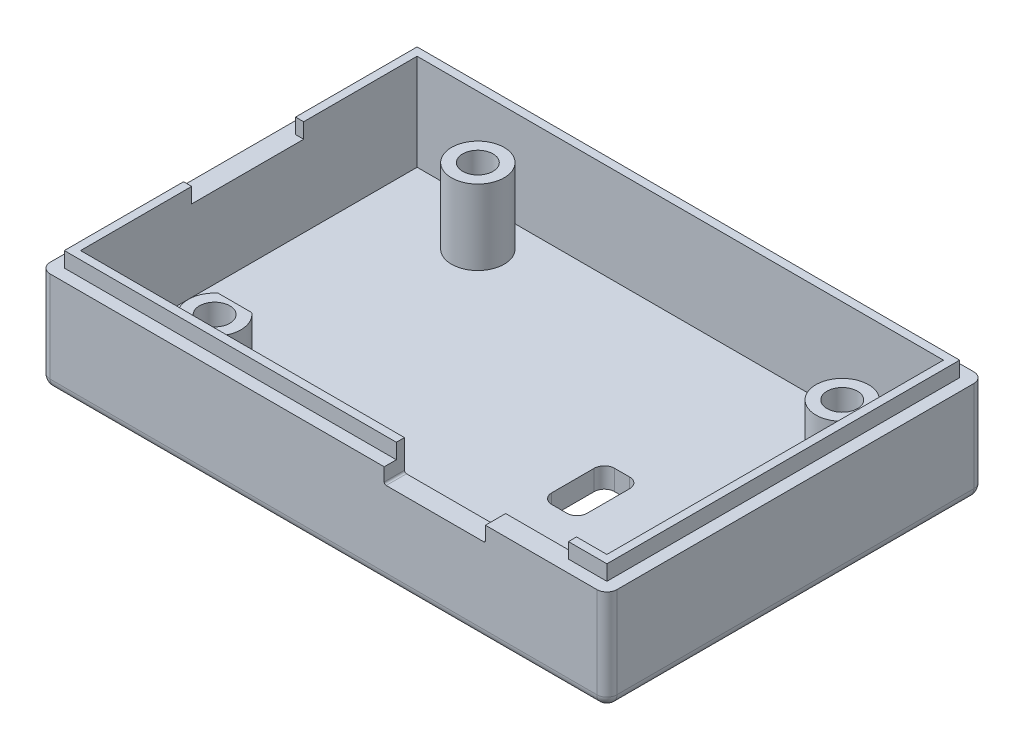
from build123d import *

# Parameters (mm, degrees)
SKETCH1_W           = 56
SKETCH1_H           = 37.25
BOSS_EXTRUDE1_DEPTH = 2
SKETCH2_W           = 56
SKETCH2_H           = 37.25
SKETCH2_W_2         = 52
SKETCH2_H_2         = 33.25
BOSS_EXTRUDE2_DEPTH = 9
SKETCH3_R           = 2.6
SKETCH3_R_2         = 1.5
BOSS_EXTRUDE3_DEPTH = 7.4
SKETCH5_W           = 56
SKETCH5_H           = 37.25
SKETCH5_W_2         = 53.6
SKETCH5_H_2         = 34.85
CUT_EXTRUDE1_DEPTH  = 1
FILLET1_R           = 1
SKETCH7_R           = 1.5
CUT_EXTRUDE2_DEPTH  = 10
CUT_EXTRUDE3_DEPTH  = 3
FILLET2_R           = 1
CUT_EXTRUDE4_DEPTH  = 7.4
SKETCH10_W          = 3.5
SKETCH10_H          = 6.2
CUT_EXTRUDE5_DEPTH  = 10
FILLET3_R           = 1
SKETCH11_W          = 7
SKETCH11_H          = 1
CUT_EXTRUDE6_DEPTH  = 10
FILLET4_R           = 0.2
BOSS_EXTRUDE6_DEPTH = 0.5
SKETCH13_W          = 11.063396545
SKETCH13_H          = 1.5
CUT_EXTRUDE9_DEPTH  = 2
SKETCH14_R          = 2.6
CUT_EXTRUDE10_DEPTH = 2.3


with BuildPart() as part:
    # Sketch1 → Boss-Extrude1 (new body)
    with BuildSketch(Plane(origin=(0, 0, 0), x_dir=(1, 0, 0), z_dir=(0, 1, 0))):
        with Locations((28, 18.625)):
            Rectangle(SKETCH1_W, SKETCH1_H)
    extrude(amount=BOSS_EXTRUDE1_DEPTH)

    # Sketch2 → Boss-Extrude2 (add)
    with BuildSketch(Plane(origin=(0, 2, 0), x_dir=(1, 0, 0), z_dir=(0, 1, 0))):
        with Locations((28, 18.625)):
            Rectangle(SKETCH2_W, SKETCH2_H)
        with Locations((28, 18.625)):
            Rectangle(SKETCH2_W_2, SKETCH2_H_2, mode=Mode.SUBTRACT)
    extrude(amount=BOSS_EXTRUDE2_DEPTH)

    # Sketch3 → Boss-Extrude3 (add)
    with BuildSketch(Plane(origin=(0, 2, 0), x_dir=(1, 0, 0), z_dir=(0, 1, 0))):
        with Locations((12, 5.25)):
            Circle(SKETCH3_R)
        with Locations((12, 5.25)):
            Circle(SKETCH3_R_2, mode=Mode.SUBTRACT)
        with Locations((12, 31.25)):
            Circle(SKETCH3_R)
        with Locations((12, 31.25)):
            Circle(SKETCH3_R_2, mode=Mode.SUBTRACT)
        with Locations((48, 31.25)):
            Circle(SKETCH3_R)
        with Locations((48, 31.25)):
            Circle(SKETCH3_R_2, mode=Mode.SUBTRACT)
    extrude(amount=BOSS_EXTRUDE3_DEPTH)

    # Sketch5 → Cut-Extrude1 (cut)
    with BuildSketch(Plane(origin=(0, 11, 0), x_dir=(1, 0, 0), z_dir=(0, 1, 0))):
        with Locations((28, 18.625)):
            Rectangle(SKETCH5_W, SKETCH5_H)
        with Locations((28, 18.625)):
            Rectangle(SKETCH5_W_2, SKETCH5_H_2, mode=Mode.SUBTRACT)
    extrude(amount=-CUT_EXTRUDE1_DEPTH, mode=Mode.SUBTRACT)

    # Fillet1
    fillet1_edges = [part.edges().sort_by_distance(p)[0] for p in [
        (0, 5, -37.25),
        (56, 5, -37.25),
        (56, 5, 0),
        (0, 5, 0),
    ]]
    fillet(fillet1_edges, radius=FILLET1_R)

    # Sketch7 → Cut-Extrude2 (cut)
    with BuildSketch(Plane(origin=(0, 2, 0), x_dir=(1, 0, 0), z_dir=(0, 1, 0))):
        with Locations((12, 5.25)):
            Circle(SKETCH7_R)
        with Locations((48, 31.25)):
            Circle(SKETCH7_R)
        with Locations((12, 31.25)):
            Circle(SKETCH7_R)
    extrude(amount=-CUT_EXTRUDE2_DEPTH, mode=Mode.SUBTRACT)

    # Sketch8 → Cut-Extrude3 (cut)
    with BuildSketch(Plane.XY):
        Polygon((44, 10), (44, 8.5), (34, 8.5), (34, 10), (34, 11), (44, 11), align=None)
    extrude(amount=-CUT_EXTRUDE3_DEPTH, mode=Mode.SUBTRACT)

    # Fillet2
    fillet2_edges = [part.edges().sort_by_distance(p)[0] for p in [
        (28, 0, -37.25),
        (0, 0, -18.625),
        (56, 0, -18.625),
        (28, 0, 0),
        (0.292893219, 0, -0.292893219),
        (0.292893219, 0, -36.957106781),
        (55.707106781, 0, -0.292893219),
        (55.707106781, 0, -36.957106781),
    ]]
    fillet(fillet2_edges, radius=FILLET2_R)

    # Sketch9 → Cut-Extrude4 (cut)
    with BuildSketch(Plane(origin=(0, 9.4, 0), x_dir=(1, 0, 0), z_dir=(0, 1, 0))):
        with BuildLine():
            Line((12, 7.25), (13.661324773, 7.25))
            ThreePointArc((13.661324773, 7.25), (12, 7.85), (10.338675227, 7.25))
            Line((10.338675227, 7.25), (12, 7.25))
        make_face()
    extrude(amount=-CUT_EXTRUDE4_DEPTH, mode=Mode.SUBTRACT)

    # Sketch10 → Cut-Extrude5 (cut)
    with BuildSketch(Plane(origin=(0, 2, 0), x_dir=(1, 0, 0), z_dir=(0, 1, 0))):
        with Locations((38.25, 16.15)):
            Rectangle(SKETCH10_W, SKETCH10_H)
    extrude(amount=-CUT_EXTRUDE5_DEPTH, mode=Mode.SUBTRACT)

    # Fillet3
    fillet3_edges = [part.edges().sort_by_distance(p)[0] for p in [
        (36.5, 1, -13.05),
        (36.5, 1, -19.25),
        (40, 1, -19.25),
        (40, 1, -13.05),
    ]]
    fillet(fillet3_edges, radius=FILLET3_R)

    # Sketch11 → Cut-Extrude6 (cut)
    with BuildSketch(Plane.XY.offset(-1.2)):
        with Locations((47.5, 10.5)):
            Rectangle(SKETCH11_W, SKETCH11_H)
    extrude(amount=-CUT_EXTRUDE6_DEPTH, mode=Mode.SUBTRACT)

    # Fillet4
    fillet4_edges = [part.edges().sort_by_distance(p)[0] for p in [
        (44, 8.5, -1),
        (34, 8.5, -1),
    ]]
    fillet(fillet4_edges, radius=FILLET4_R)

    # Sketch12 → Boss-Extrude6 (add)
    with BuildSketch(Plane(origin=(0, 11, 0), x_dir=(1, 0, 0), z_dir=(0, 1, 0))):
        Polygon((51, 2), (51, 1.2), (54.8, 1.2), (54.8, 36.05), (1.2, 36.05), (1.2, 1.2), (34, 1.2), (34, 2), (2, 2), (2, 35.25), (54, 35.25), (54, 2), align=None)
    extrude(amount=BOSS_EXTRUDE6_DEPTH)

    # Sketch13 → Cut-Extrude9 (cut)
    with BuildSketch(Plane.ZY.offset(-1.2)):
        with Locations((-18.511698272, 10.75)):
            Rectangle(SKETCH13_W, SKETCH13_H)
    extrude(amount=-CUT_EXTRUDE9_DEPTH, mode=Mode.SUBTRACT)

    # Sketch14 → Cut-Extrude10 (cut)
    with BuildSketch(Plane(origin=(0, 9.4, 0), x_dir=(1, 0, 0), z_dir=(0, 1, 0))):
        with Locations((48, 31.25)):
            Circle(SKETCH14_R)
    extrude(amount=-CUT_EXTRUDE10_DEPTH, mode=Mode.SUBTRACT)


solid = part.part
